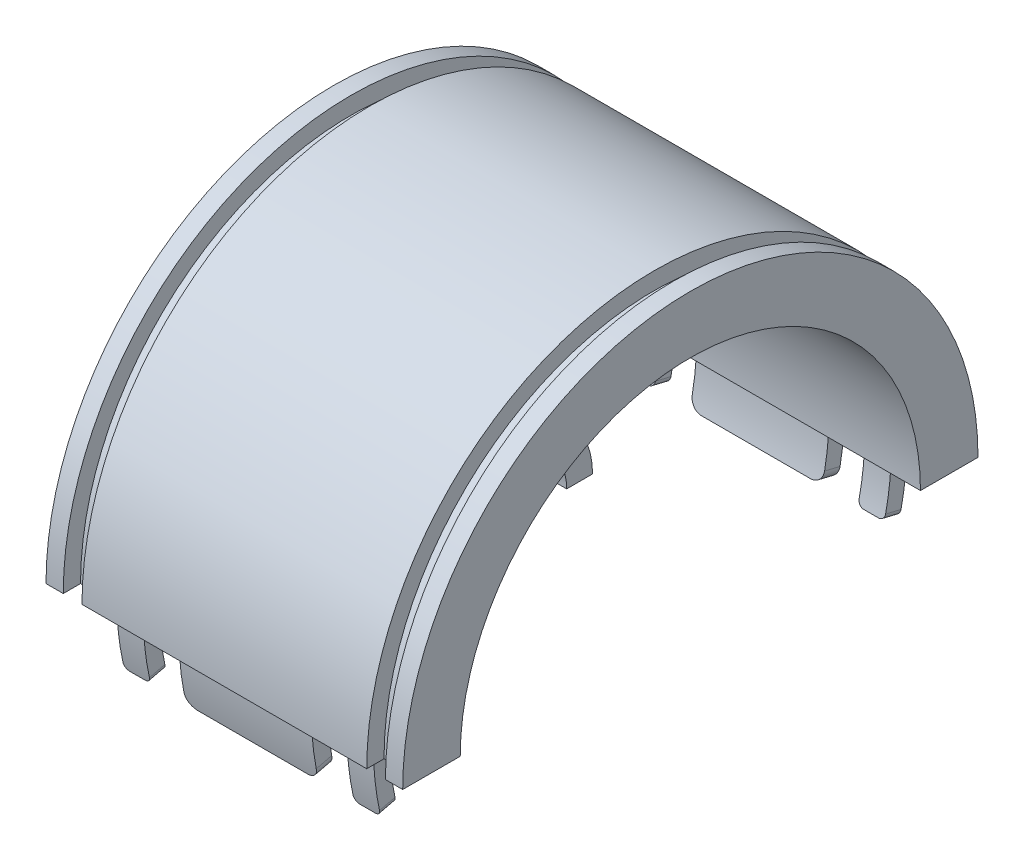
from build123d import *

# Parameters (mm, degrees)
REVOLVE1_ANGLE      = 180
SKETCH2_W           = 23
SKETCH2_H           = 2.76
SKETCH2_W_2         = 4.6
REVOLVE2_ANGLE      = 13.5
FILLET1_R           = 2
FILLET3_R           = 2
BOSS_EXTRUDE1_DEPTH = 31
CUT_EXTRUDE2_DEPTH  = 74
CIRPATTERN2_COUNT   = 6
FILLET4_R           = 1


with BuildPart() as part:
    # Sketch1 → Revolve1 (revolve)
    with BuildSketch(Plane(origin=(0, 0, 0), x_dir=(1, 0, 0), z_dir=(0, 1, 0))):
        with BuildLine():
            Line((24.75, 47), (28, 47))
            Line((28, 47), (28, 50))
            Line((28, 50), (31, 50))
            Line((31, 50), (31, 40))
            Line((31, 40), (-26, 40))
            add(Edge.make_bspline(
                [(-26, 40), (-27.013739482, 36.809226409), (-29.345099443, 27.828113636), (-24.523456801, 15.394699457), (-15.526264119, 14.868541835), (-9.946885113, 14)],
                knots=[0, 0, 0, 0, 0.285238859, 0.456571244, 0.779817638, 0.779817638, 0.779817638, 0.779817638], degree=3))
            Line((-9.946885113, 14), (-10, 9.5))
            add(Edge.make_bspline(
                [(-31, 40), (-32.939614555, 37.540591148), (-36.933922801, 27.582274875), (-30.082407751, 11.775662378), (-17.92187093, 9.5), (-10, 9.5)],
                knots=[0, 0, 0, 0, 0.268184782, 0.444494999, 0.822560414, 0.822560414, 0.822560414, 0.822560414], degree=3))
            Line((-31, 40), (-31, 50))
            Line((-31, 50), (-28, 50))
            Line((-28, 50), (-28, 47))
            Line((-28, 47), (-24.75, 47))
            Line((-24.75, 47), (-24.75, 50))
            Line((-24.75, 50), (24.75, 50))
            Line((24.75, 50), (24.75, 47))
        make_face()
    revolve(axis=Axis((0, 0, 0), (1, 0, 0)), revolution_arc=REVOLVE1_ANGLE)

    # Sketch2 → Revolve2 (revolve)
    with BuildSketch(Plane(origin=(0, 0, 0), x_dir=(-1, 0, 0), z_dir=(0, -1, 0))):
        with Locations((0, -45)):
            Rectangle(SKETCH2_W, SKETCH2_H)
        with Locations((20, -45)):
            Rectangle(SKETCH2_W_2, SKETCH2_H)
        with Locations((-20, -45)):
            Rectangle(SKETCH2_W_2, SKETCH2_H)
    revolve2 = revolve(axis=Axis((0, 0, 0), (1, 0, 0)), revolution_arc=REVOLVE2_ANGLE)

    # Fillet1
    fillet1_edges = [part.edges().sort_by_distance(p)[0] for p in [
        (-11.5, -10.505041374, 43.756646418),
        (11.5, -10.505041374, 43.756646418),
    ]]
    fillet(fillet1_edges, radius=FILLET1_R)

    # Mirror4: Revolve2 across plane
    add(revolve2.mirror(Plane.XY))

    # Fillet3
    fillet3_edges = [part.edges().sort_by_distance(p)[0] for p in [
        (-11.5, -10.505041374, -43.756646418),
        (11.5, -10.505041374, -43.756646418),
    ]]
    fillet(fillet3_edges, radius=FILLET3_R)

    # Sketch6 → Boss-Extrude1 (add)
    with BuildSketch(Plane(origin=(0, 0, 0), x_dir=(0, 0, -1), z_dir=(1, 0, 0))):
        with BuildLine():
            Line((-14, 0), (-9.5, 0))
            ThreePointArc((-9.5, 0), (0, 9.5), (9.5, 0))
            Line((9.5, 0), (14, 0))
            ThreePointArc((14, 0), (0, 14), (-14, 0))
        make_face()
    extrude(amount=-BOSS_EXTRUDE1_DEPTH)

    # Sketch7 → Cut-Extrude2 (cut)
    with BuildSketch(Plane(origin=(31, 0, 0), x_dir=(0, 0, -1), z_dir=(1, 0, 0))):
        with BuildLine():
            Line((4.788282007, 13.155696691), (13.680805733, 37.587704831))
            ThreePointArc((13.680805733, 37.587704831), (0, 40), (-13.680805733, 37.587704831))
            Line((-13.680805733, 37.587704831), (-4.788282007, 13.155696691))
            ThreePointArc((-4.788282007, 13.155696691), (0, 14), (4.788282007, 13.155696691))
        make_face()
    cut_extrude2 = extrude(amount=-CUT_EXTRUDE2_DEPTH, mode=Mode.SUBTRACT)

    # CirPattern2: Cut-Extrude2 ×6 about axis
    cirpattern2_axis = Axis((0, 0, 0), (1, 0, 0))
    for i in range(1, CIRPATTERN2_COUNT):
        add(cut_extrude2.rotate(cirpattern2_axis, i * 360 / CIRPATTERN2_COUNT), mode=Mode.SUBTRACT)

    # Fillet4
    fillet4_edges = [part.edges().sort_by_distance(p)[0] for p in [
        (22.3, -10.505041374, -43.756646418),
        (17.7, -10.505041374, -43.756646418),
        (-22.3, -10.505041374, -43.756646418),
        (-17.7, -10.505041374, -43.756646418),
        (22.3, -10.505041374, 43.756646418),
        (17.7, -10.505041374, 43.756646418),
        (-22.3, -10.505041374, 43.756646418),
        (-17.7, -10.505041374, 43.756646418),
    ]]
    fillet(fillet4_edges, radius=FILLET4_R)


solid = part.part
